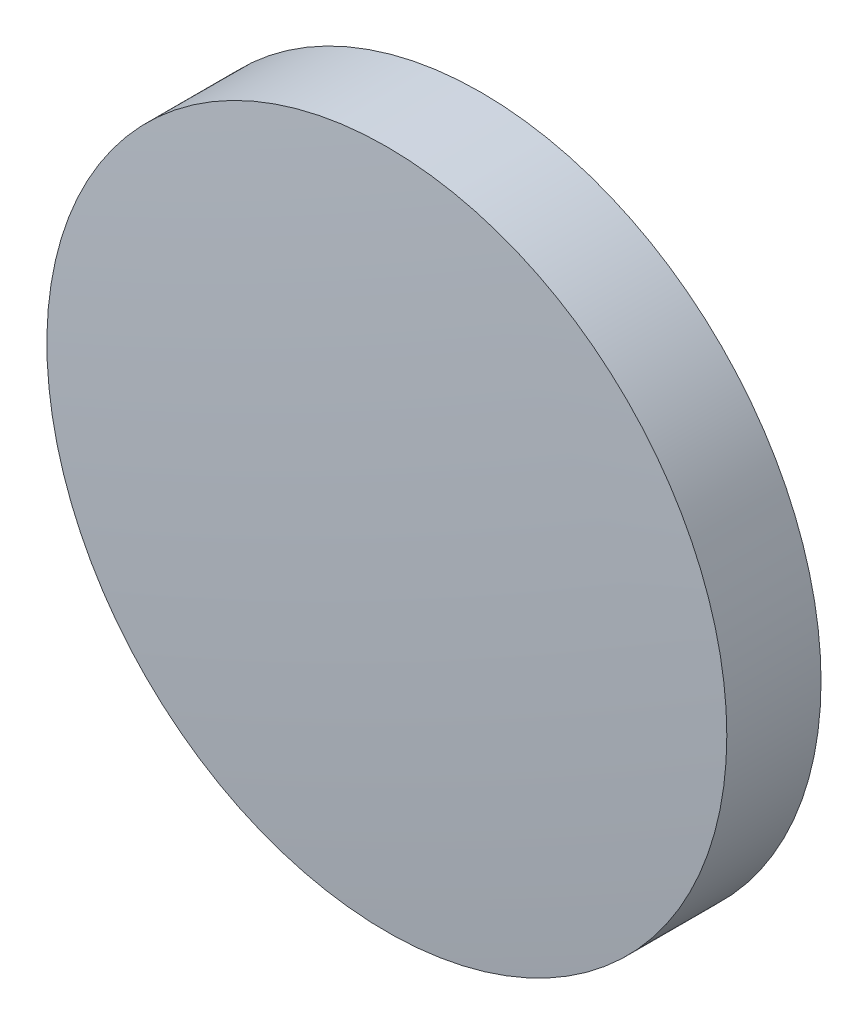
from build123d import *


with BuildPart() as part:
    # Sketch2 → Revolve1 (revolve)
    with BuildSketch(Plane(origin=(0, 0, 0), x_dir=(0, 0, -1), z_dir=(1, 0, 0))):
        with BuildLine():
            Line((-1.1, 0), (1.1, 0))
            ThreePointArc((1.1, 0), (1.044952186, 3.176907108), (0.879874836, 6.35))
            Line((0.879874836, 6.35), (-0.879874836, 6.35))
            ThreePointArc((-0.879874836, 6.35), (-1.044952186, 3.176907108), (-1.1, 0))
        make_face()
    revolve(axis=Axis((0, 0, 1.1), (0, 0, -1)))


solid = part.part
